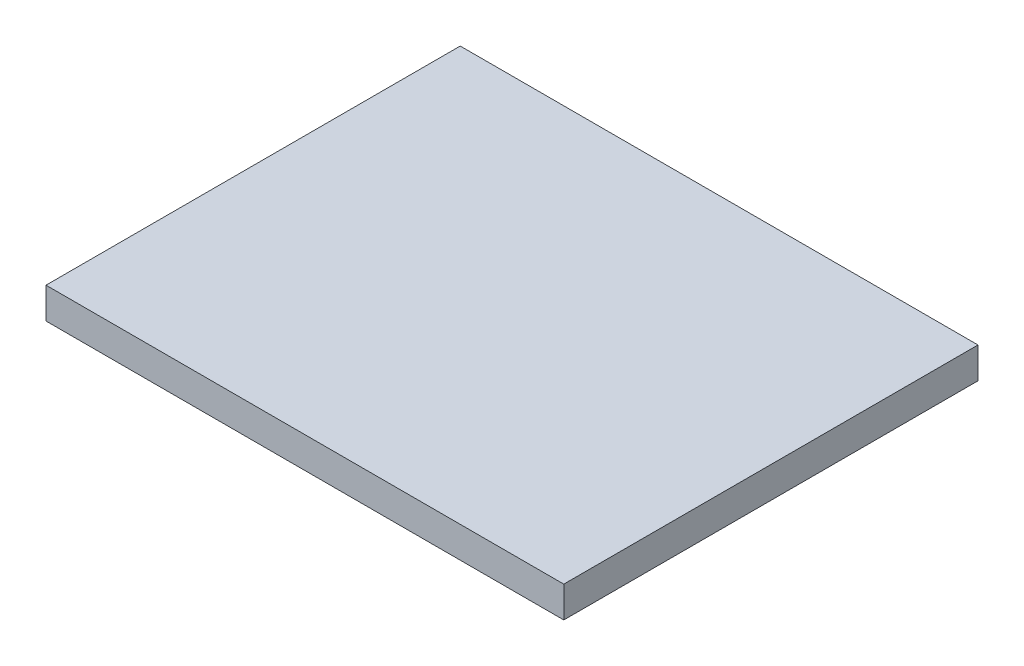
from build123d import *

# Parameters (mm, degrees)
SKETCH1_W           = 100
SKETCH1_H           = 80
BOSS_EXTRUDE1_DEPTH = 6


with BuildPart() as part:
    # Sketch1 → Boss-Extrude1 (new body)
    with BuildSketch(Plane(origin=(0, 0, 0), x_dir=(1, 0, 0), z_dir=(0, 1, 0))):
        with Locations((-40.804597701, 35.574712644)):
            Rectangle(SKETCH1_W, SKETCH1_H)
    extrude(amount=BOSS_EXTRUDE1_DEPTH)


solid = part.part
